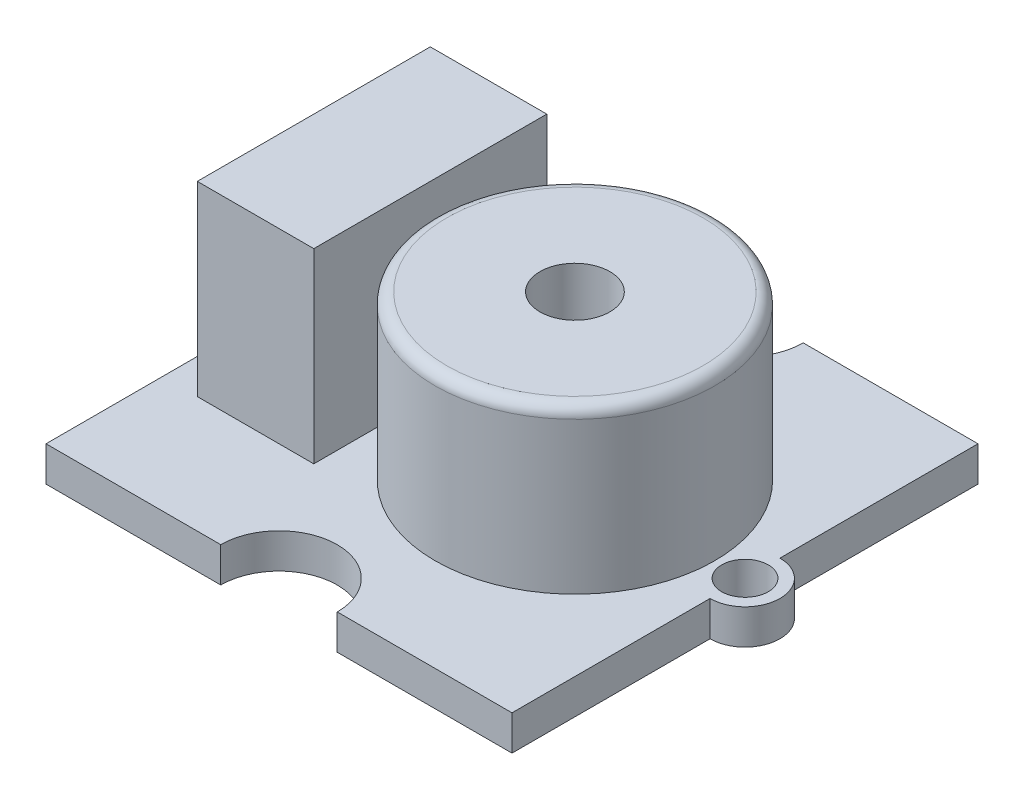
from build123d import *

# Parameters (mm, degrees)
SKETCH3_W           = 20
SKETCH3_H           = 20
BOSS_EXTRUDE1_DEPTH = 1.5
SKETCH4_R           = 1.5
BOSS_EXTRUDE2_DEPTH = 1.5
SKETCH5_R           = 1
SKETCH5_R_2         = 2.5
CUT_EXTRUDE1_DEPTH  = 1.5
SKETCH6_W           = 5
SKETCH6_H           = 10
BOSS_EXTRUDE3_DEPTH = 8
SKETCH7_R           = 6
BOSS_EXTRUDE4_DEPTH = 7
FILLET1_R           = 0.5
SKETCH8_R           = 1.5
CUT_EXTRUDE2_DEPTH  = 3


with BuildPart() as part:
    # Sketch3 → Boss-Extrude1 (new body)
    with BuildSketch(Plane(origin=(0, 0, 0), x_dir=(1, 0, 0), z_dir=(0, 1, 0))):
        Rectangle(SKETCH3_W, SKETCH3_H)
    extrude(amount=BOSS_EXTRUDE1_DEPTH)

    # Sketch4 → Boss-Extrude2 (add)
    with BuildSketch(Plane(origin=(0, 1.5, 0), x_dir=(1, 0, 0), z_dir=(0, 1, 0))):
        with Locations((-10, 0)):
            Circle(SKETCH4_R)
        with Locations((10, 0)):
            Circle(SKETCH4_R)
    extrude(amount=-BOSS_EXTRUDE2_DEPTH)

    # Sketch5 → Cut-Extrude1 (cut)
    with BuildSketch(Plane(origin=(0, 1.5, 0), x_dir=(1, 0, 0), z_dir=(0, 1, 0))):
        with Locations((-10, 0)):
            Circle(SKETCH5_R)
        with Locations((10, 0)):
            Circle(SKETCH5_R)
        with Locations((0, 10)):
            Circle(SKETCH5_R_2)
        with Locations((0, -10)):
            Circle(SKETCH5_R_2)
    extrude(amount=-CUT_EXTRUDE1_DEPTH, mode=Mode.SUBTRACT)

    # Sketch6 → Boss-Extrude3 (add)
    with BuildSketch(Plane(origin=(0, 1.5, 0), x_dir=(1, 0, 0), z_dir=(0, 1, 0))):
        with Locations((-6.006775527, 0)):
            Rectangle(SKETCH6_W, SKETCH6_H)
    extrude(amount=BOSS_EXTRUDE3_DEPTH)

    # Sketch7 → Boss-Extrude4 (add)
    with BuildSketch(Plane(origin=(0, 1.5, 0), x_dir=(1, 0, 0), z_dir=(0, 1, 0))):
        with Locations((2.7, 0)):
            Circle(SKETCH7_R)
    extrude(amount=BOSS_EXTRUDE4_DEPTH)

    # Fillet1
    fillet1_edges = [part.edges().sort_by_distance(p)[0] for p in [
        (-3.3, 8.5, 0),
    ]]
    fillet(fillet1_edges, radius=FILLET1_R)

    # Sketch8 → Cut-Extrude2 (cut)
    with BuildSketch(Plane(origin=(0, 8.5, 0), x_dir=(1, 0, 0), z_dir=(0, 1, 0))):
        with Locations((2.7, 0)):
            Circle(SKETCH8_R)
    extrude(amount=-CUT_EXTRUDE2_DEPTH, mode=Mode.SUBTRACT)


solid = part.part
